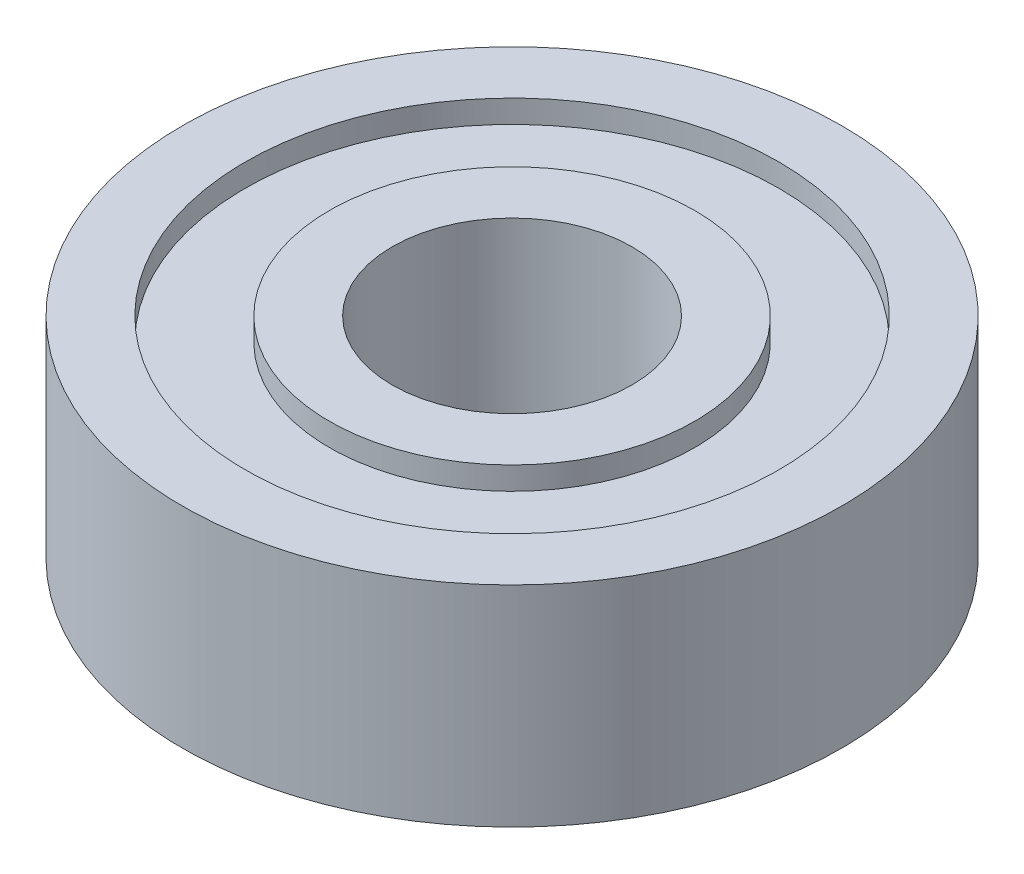
from build123d import *


with BuildPart() as part:
    # Sketch1 → Revolve1 (revolve)
    with BuildSketch(Plane.XY):
        Polygon((11, -3.5), (11, 3.5), (8.904, 3.5), (8.904, 2.738), (6.096, 2.738), (6.096, 3.5), (4, 3.5), (4, -3.5), (6.096, -3.5), (6.096, -2.738), (8.904, -2.738), (8.904, -3.5), align=None)
    revolve(axis=Axis((0, 0, 0), (0, 1, 0)))


solid = part.part
